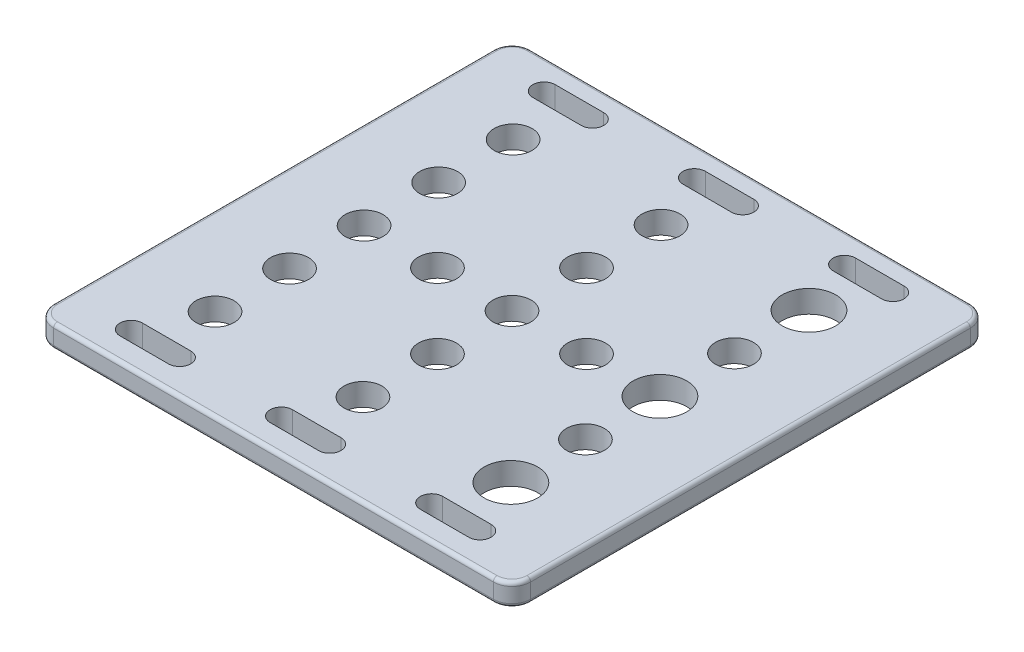
from build123d import *

# Parameters (mm, degrees)
SKETCH1_R           = 2.55
SKETCH1_R_2         = 3.6
BOSS_EXTRUDE1_DEPTH = 3
FILLET1_R           = 0.5


with BuildPart() as part:
    # Sketch1 → Boss-Extrude1 (new body)
    with BuildSketch(Plane(origin=(0, 0, 0), x_dir=(1, 0, 0), z_dir=(0, 1, 0))):
        with BuildLine():
            Line((29.5, 32), (-29.5, 32))
            ThreePointArc((-29.5, 32), (-31.267766953, 31.267766953), (-32, 29.5))
            Line((-32, 29.5), (-32, -29.5))
            ThreePointArc((-32, -29.5), (-31.267766953, -31.267766953), (-29.5, -32))
            Line((-29.5, -32), (29.5, -32))
            ThreePointArc((29.5, -32), (31.267766953, -31.267766953), (32, -29.5))
            Line((32, -29.5), (32, 29.5))
            ThreePointArc((32, 29.5), (31.267766953, 31.267766953), (29.5, 32))
        make_face()
        with Locations((-10.25, 0.25)):
            Circle(SKETCH1_R, mode=Mode.SUBTRACT)
        with Locations((19.6, 0.25)):
            Circle(SKETCH1_R_2, mode=Mode.SUBTRACT)
        with Locations((19.6, 10.25)):
            Circle(SKETCH1_R, mode=Mode.SUBTRACT)
        with Locations((-0.25, 10.25)):
            Circle(SKETCH1_R, mode=Mode.SUBTRACT)
        with Locations((19.6, -19.75)):
            Circle(SKETCH1_R_2, mode=Mode.SUBTRACT)
        with Locations((-0.25, -9.75)):
            Circle(SKETCH1_R, mode=Mode.SUBTRACT)
        with Locations((19.6, -9.75)):
            Circle(SKETCH1_R, mode=Mode.SUBTRACT)
        with Locations((9.75, 0.25)):
            Circle(SKETCH1_R, mode=Mode.SUBTRACT)
        with Locations((-0.25, 0.25)):
            Circle(SKETCH1_R, mode=Mode.SUBTRACT)
        with Locations((-20.1, -19.75)):
            Circle(SKETCH1_R, mode=Mode.SUBTRACT)
        with Locations((-20.1, -9.75)):
            Circle(SKETCH1_R, mode=Mode.SUBTRACT)
        with Locations((-20.1, 0.25)):
            Circle(SKETCH1_R, mode=Mode.SUBTRACT)
        with Locations((-20.1, 10.25)):
            Circle(SKETCH1_R, mode=Mode.SUBTRACT)
        with Locations((19.6, 20.25)):
            Circle(SKETCH1_R_2, mode=Mode.SUBTRACT)
        with Locations((-20.1, 20.25)):
            Circle(SKETCH1_R, mode=Mode.SUBTRACT)
        with Locations((-0.25, -19.75)):
            Circle(SKETCH1_R, mode=Mode.SUBTRACT)
        with Locations((-0.25, 20.25)):
            Circle(SKETCH1_R, mode=Mode.SUBTRACT)
        with BuildLine():
            Line((3, 26.45), (-3.500000052, 26.45))
            ThreePointArc((-3.500000052, 26.45), (-5.000000052, 27.95), (-3.500000052, 29.45))
            Line((-3.500000052, 29.45), (3, 29.45))
            ThreePointArc((3, 29.45), (4.5, 27.95), (3, 26.45))
        make_face(mode=Mode.SUBTRACT)
        with BuildLine():
            Line((-23.649999471, 29.45), (-17.15, 29.45))
            ThreePointArc((-17.15, 29.45), (-15.65, 27.95), (-17.15, 26.45))
            Line((-17.15, 26.45), (-23.649999471, 26.45))
            ThreePointArc((-23.649999471, 26.45), (-25.149999471, 27.95), (-23.649999471, 29.45))
        make_face(mode=Mode.SUBTRACT)
        with BuildLine():
            Line((16.649999628, 29.45), (23.15, 29.45))
            ThreePointArc((23.15, 29.45), (24.65, 27.95), (23.15, 26.45))
            Line((23.15, 26.45), (16.649999628, 26.45))
            ThreePointArc((16.649999628, 26.45), (15.149999628, 27.95), (16.649999628, 29.45))
        make_face(mode=Mode.SUBTRACT)
        with BuildLine():
            Line((-17.15, -28.95), (-23.649999471, -28.95))
            ThreePointArc((-23.649999471, -28.95), (-25.149999471, -27.45), (-23.649999471, -25.95))
            Line((-23.649999471, -25.95), (-17.15, -25.95))
            ThreePointArc((-17.15, -25.95), (-15.65, -27.45), (-17.15, -28.95))
        make_face(mode=Mode.SUBTRACT)
        with BuildLine():
            Line((-3.500000052, -25.95), (3, -25.95))
            ThreePointArc((3, -25.95), (4.5, -27.45), (3, -28.95))
            Line((3, -28.95), (-3.500000052, -28.95))
            ThreePointArc((-3.500000052, -28.95), (-5.000000052, -27.45), (-3.500000052, -25.95))
        make_face(mode=Mode.SUBTRACT)
        with BuildLine():
            Line((23.15, -28.95), (16.649999628, -28.95))
            ThreePointArc((16.649999628, -28.95), (15.149999628, -27.45), (16.649999628, -25.95))
            Line((16.649999628, -25.95), (23.15, -25.95))
            ThreePointArc((23.15, -25.95), (24.65, -27.45), (23.15, -28.95))
        make_face(mode=Mode.SUBTRACT)
    extrude(amount=BOSS_EXTRUDE1_DEPTH)

    # Fillet1
    fillet1_edges = [part.edges().sort_by_distance(p)[0] for p in [
        (-32, 0, 0),
        (-31.267766953, 0, -31.267766953),
        (0, 0, -32),
        (31.267766953, 0, -31.267766953),
        (-31.267766953, 3, -31.267766953),
        (-32, 3, 0),
        (-31.267766953, 3, 31.267766953),
        (0, 3, 32),
        (31.267766953, 3, 31.267766953),
        (32, 3, 0),
        (31.267766953, 3, -31.267766953),
        (32, 0, 0),
        (0, 3, -32),
        (31.267766953, 0, 31.267766953),
        (0, 0, 32),
        (-31.267766953, 0, 31.267766953),
    ]]
    fillet(fillet1_edges, radius=FILLET1_R)


solid = part.part
